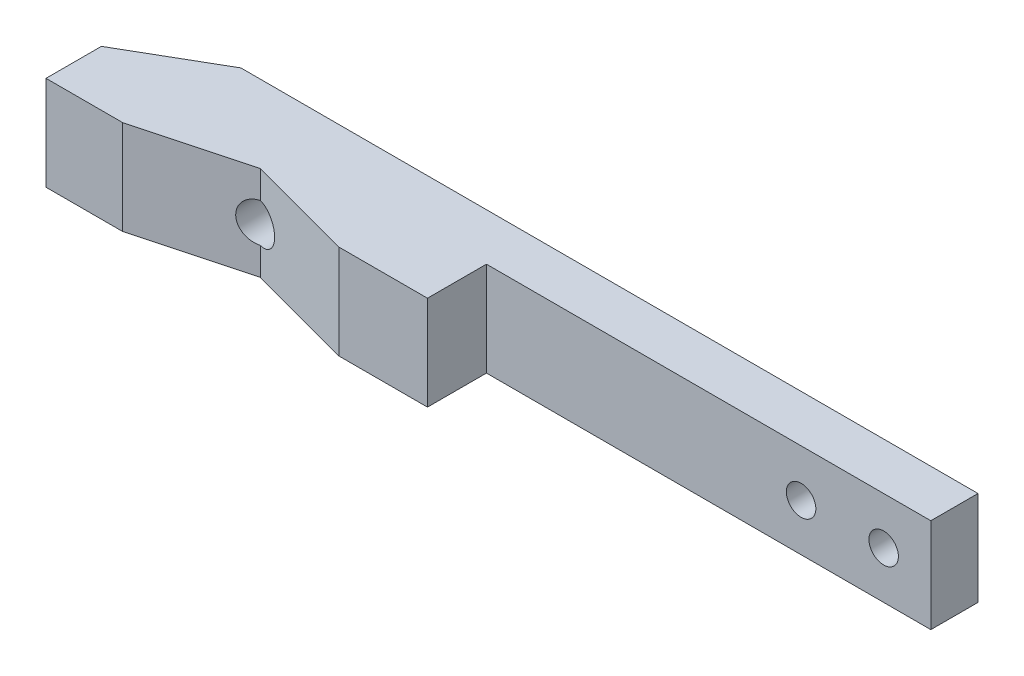
from build123d import *

# Parameters (mm, degrees)
BOSS_EXTRUDE2_DEPTH   = 8
M3_TAPPED_HOLE1_D     = 2.5
M3_TAPPED_HOLE1_DEPTH = 8.5
M3_TAPPED_HOLE1_TIP   = 0.751075774
M4_TAPPED_HOLE1_D     = 3.3
M4_TAPPED_HOLE1_DEPTH = 11.5
M4_TAPPED_HOLE1_TIP   = 0.991420021


with BuildPart() as part:
    # Sketch1 → Boss-Extrude2 (new body)
    with BuildSketch(Plane(origin=(0, 0, 0), x_dir=(1, 0, 0), z_dir=(0, 1, 0))):
        Polygon((35.397046685, 0.212206196), (35.397046685, -3.787793804), (-2.283249607, -3.787793804), (-2.283249607, -8.787793804), (-9.783249607, -8.787793804), (-18.892613672, -6.346947059), (-28.102933344, -8.814844777), (-34.602933344, -8.814844777), (-34.602933344, -4.117707659), (-27.103302555, 0.212206196), align=None)
    extrude(amount=BOSS_EXTRUDE2_DEPTH)

    # M3 Tapped Hole1
    with Locations(Plane(origin=(0, 0, -0.212206196), x_dir=(-1, 0, 0), z_dir=(0, 0, -1))):
        with Locations((-31.397046685, 4), (-24.397046685, 4)):
            Hole(M3_TAPPED_HOLE1_D / 2, depth=M3_TAPPED_HOLE1_DEPTH)
            with Locations((0, 0, -(M3_TAPPED_HOLE1_DEPTH + M3_TAPPED_HOLE1_TIP / 2))):  # 118° drill point
                Cone(0, M3_TAPPED_HOLE1_D / 2, M3_TAPPED_HOLE1_TIP, mode=Mode.SUBTRACT)

    # M4 Tapped Hole1
    with Locations(Plane(origin=(0, 0, -0.212206196), x_dir=(-1, 0, 0), z_dir=(0, 0, -1))):
        with Locations((18.892933344, 4)):
            Hole(M4_TAPPED_HOLE1_D / 2, depth=M4_TAPPED_HOLE1_DEPTH)
            with Locations((0, 0, -(M4_TAPPED_HOLE1_DEPTH + M4_TAPPED_HOLE1_TIP / 2))):  # 118° drill point
                Cone(0, M4_TAPPED_HOLE1_D / 2, M4_TAPPED_HOLE1_TIP, mode=Mode.SUBTRACT)


solid = part.part
